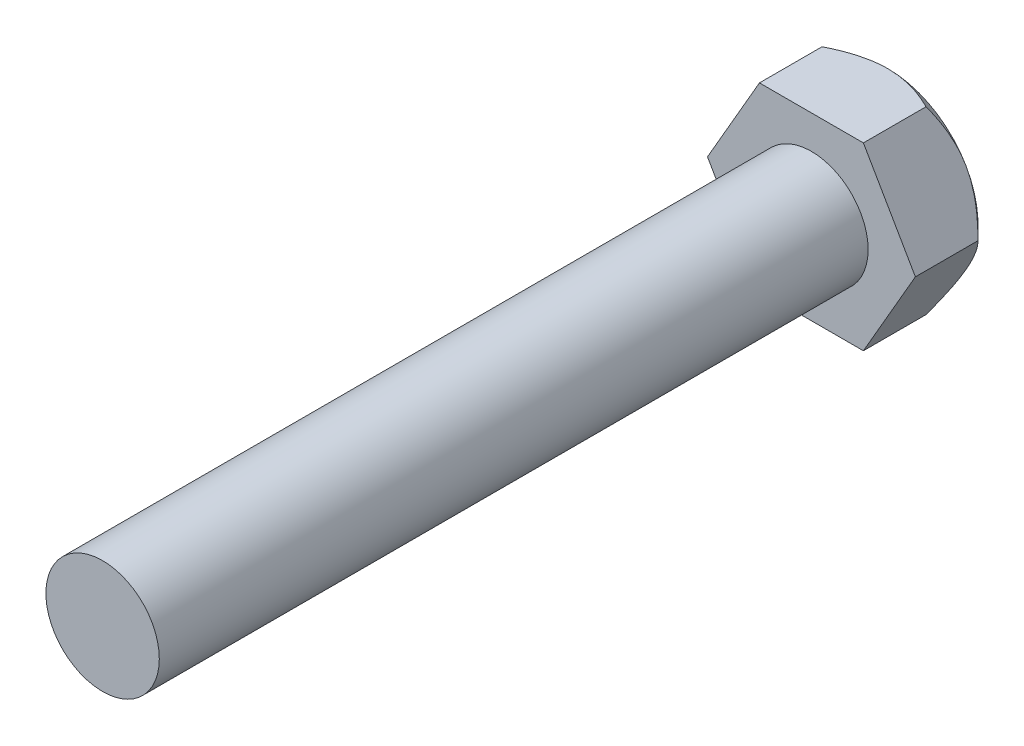
from build123d import *

# Parameters (mm, degrees)
RESSALTO_EXTRUS_O1_DEPTH = 5.4
ESBO_O2_R                = 4
RESSALTO_EXTRUS_O2_DEPTH = 50
ESBO_O3_OUTSIDE_W        = 158.404
ESBO_O3_OUTSIDE_H        = 156.44
ESBO_O3_OUTSIDE_R        = 6.35
CORTE_EXTRUS_O1_DEPTH    = 65
CORTE_EXTRUS_O1_TAPER    = 45


with BuildPart() as part:
    # Esboço1 → Ressalto-extrusão1 (new body)
    with BuildSketch(Plane.XY):
        Polygon((3.666174209, -6.35), (7.332348419, 0), (3.666174209, 6.35), (-3.666174209, 6.35), (-7.332348419, 0), (-3.666174209, -6.35), align=None)
    extrude(amount=RESSALTO_EXTRUS_O1_DEPTH)

    # Esboço2 → Ressalto-extrusão2 (add)
    with BuildSketch(Plane.XY.offset(5.4)):
        Circle(ESBO_O2_R)
    extrude(amount=RESSALTO_EXTRUS_O2_DEPTH)

    # Esboço3 outside → Corte-extrusão1 (cut)
    with BuildSketch(Plane(origin=(0, 0, 0), x_dir=(-1, 0, 0), z_dir=(0, 0, -1))):
        Rectangle(ESBO_O3_OUTSIDE_W, ESBO_O3_OUTSIDE_H)
        Circle(ESBO_O3_OUTSIDE_R, mode=Mode.SUBTRACT)
    extrude(amount=-CORTE_EXTRUS_O1_DEPTH, taper=CORTE_EXTRUS_O1_TAPER, mode=Mode.SUBTRACT)


solid = part.part
